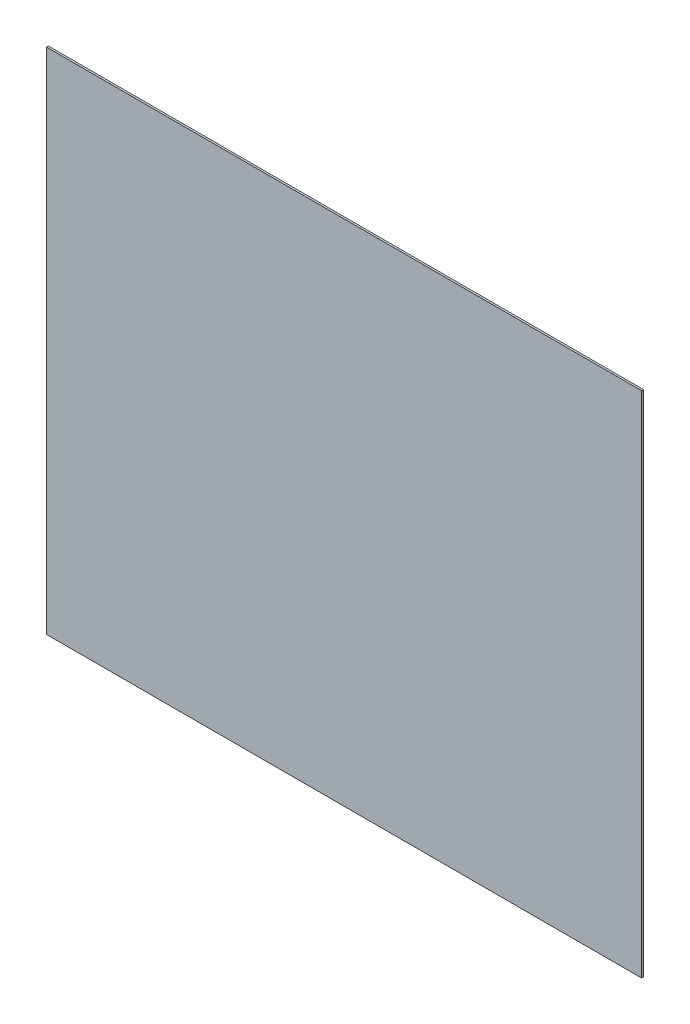
from build123d import *

# Parameters (mm, degrees)
SKETCH1_W           = 620
SKETCH1_H           = 530
BOSS_EXTRUDE1_DEPTH = 2


with BuildPart() as part:
    # Sketch1 → Boss-Extrude1 (new body)
    with BuildSketch(Plane.XY):
        with Locations((310, 265)):
            Rectangle(SKETCH1_W, SKETCH1_H)
    extrude(amount=BOSS_EXTRUDE1_DEPTH)


solid = part.part
